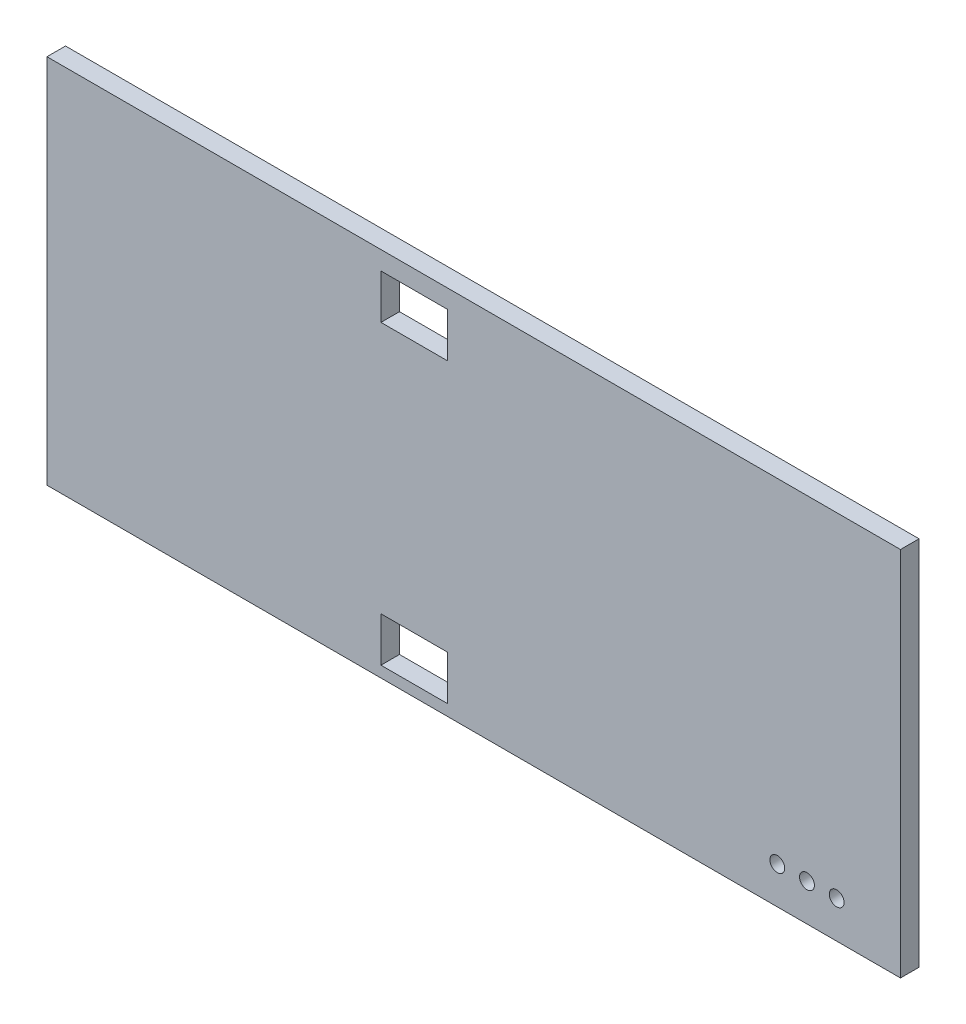
from build123d import *

# Parameters (mm, degrees)
SKETCH1_W           = 292.1
SKETCH1_H           = 127
BOSS_EXTRUDE1_DEPTH = 6.35
SKETCH2_W           = 22.86
SKETCH2_H           = 15.24
CUT_EXTRUDE1_DEPTH  = 6.35
LPATTERN1_COUNT     = 2
LPATTERN1_PITCH     = 101.6
SKETCH3_R           = 2.54
CUT_EXTRUDE2_DEPTH  = 7.35


with BuildPart() as part:
    # Sketch1 → Boss-Extrude1 (new body)
    with BuildSketch(Plane.XY):
        with Locations((146.05, 63.5)):
            Rectangle(SKETCH1_W, SKETCH1_H)
    extrude(amount=BOSS_EXTRUDE1_DEPTH)

    # Sketch2 → Cut-Extrude1 (cut)
    with BuildSketch(Plane.XY.offset(6.35)):
        with Locations((125.73, 11.43)):
            Rectangle(SKETCH2_W, SKETCH2_H)
    cut_extrude1 = extrude(amount=-CUT_EXTRUDE1_DEPTH, mode=Mode.SUBTRACT)

    # LPattern1: Cut-Extrude1 ×2
    with Locations(*[(0, i * LPATTERN1_PITCH, 0) for i in range(1, LPATTERN1_COUNT)]):
        add(cut_extrude1, mode=Mode.SUBTRACT)

    # Sketch3 → Cut-Extrude2 (cut, through all)
    with BuildSketch(Plane.XY.offset(6.35)):
        with Locations((249.94060771, 12.7)):
            Circle(SKETCH3_R)
        with Locations((260.10060771, 12.7)):
            Circle(SKETCH3_R)
        with Locations((270.26060771, 12.7)):
            Circle(SKETCH3_R)
    extrude(amount=-CUT_EXTRUDE2_DEPTH, mode=Mode.SUBTRACT)


solid = part.part
